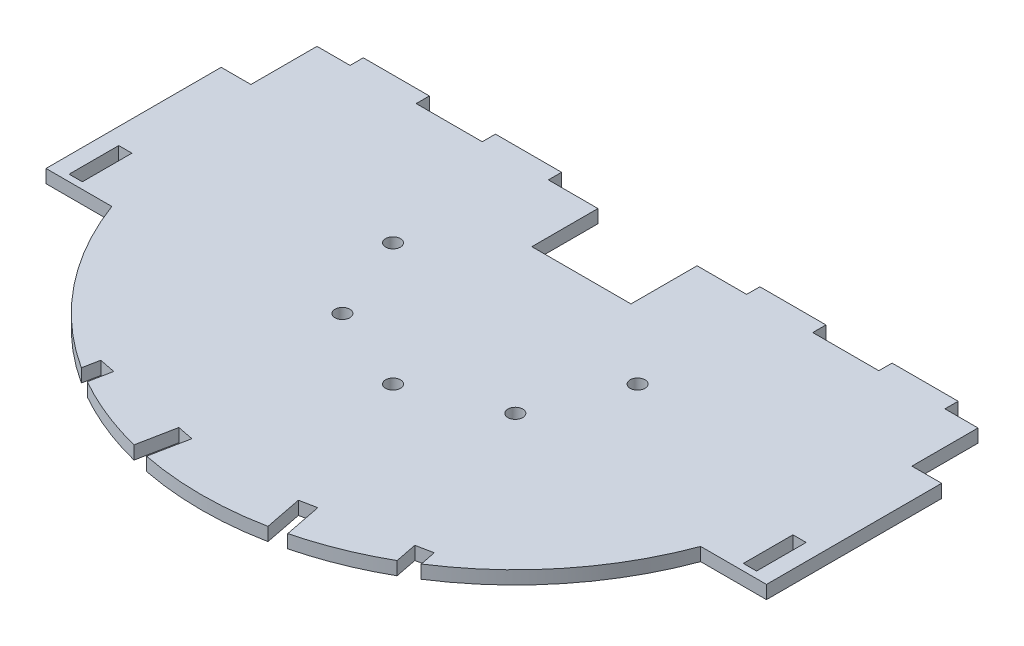
from build123d import *

# Parameters (mm, degrees)
SKICA1_W                = 4
SKICA1_H                = 15
SKICA1_R                = 2.25
P_IDAT_VYSUNUT_M1_DEPTH = 4


with BuildPart() as part:
    # Skica1 → Přidat vysunutím1 (new body)
    with BuildSketch(Plane(origin=(0, 0, 0), x_dir=(1, 0, 0), z_dir=(0, 1, 0))):
        with BuildLine():
            ThreePointArc((10.915770195, 0), (25.940686176, -26.499731394), (48.580654593, -46.881480444))
            Line((48.580654593, -46.881480444), (49.547625125, -41.975874672))
            Line((49.547625125, -41.975874672), (54.453230897, -42.942845204))
            Line((54.453230897, -42.942845204), (53.134056197, -49.635242551))
            ThreePointArc((53.134056197, -49.635242551), (64.622092485, -55.166907964), (76.747418364, -59.110354723))
            Line((76.747418364, -59.110354723), (78.981259757, -47.777697862))
            Line((78.981259757, -47.777697862), (83.886865529, -48.744668394))
            Line((83.886865529, -48.744668394), (81.627559896, -60.206509669))
            ThreePointArc((81.627559896, -60.206509669), (100, -62), (118.372440104, -60.206509669))
            Line((118.372440104, -60.206509669), (116.113134471, -48.744668394))
            Line((116.113134471, -48.744668394), (121.018740243, -47.777697862))
            Line((121.018740243, -47.777697862), (123.252581636, -59.110354723))
            ThreePointArc((123.252581636, -59.110354723), (135.377907515, -55.166907964), (146.865943803, -49.635242551))
            Line((146.865943803, -49.635242551), (145.546769103, -42.942845204))
            Line((145.546769103, -42.942845204), (150.452374875, -41.975874672))
            Line((150.452374875, -41.975874672), (151.419345407, -46.881480444))
            ThreePointArc((151.419345407, -46.881480444), (174.059313824, -26.499731394), (189.084229805, 0))
            Line((189.084229805, 0), (209, 0))
            Line((209, 0), (209, 53))
            Line((209, 53), (200, 53))
            Line((200, 53), (200, 73))
            Line((200, 73), (190, 73))
            Line((190, 73), (190, 77))
            Line((190, 77), (170, 77))
            Line((170, 77), (170, 73))
            Line((170, 73), (150, 73))
            Line((150, 73), (150, 77))
            Line((150, 77), (130, 77))
            Line((130, 77), (130, 73))
            Line((130, 73), (115, 73))
            Line((115, 73), (115, 53))
            Line((115, 53), (85, 53))
            Line((85, 53), (85, 73))
            Line((85, 73), (70, 73))
            Line((70, 73), (70, 77))
            Line((70, 77), (50, 77))
            Line((50, 77), (50, 73))
            Line((50, 73), (30, 73))
            Line((30, 73), (30, 77))
            Line((30, 77), (10, 77))
            Line((10, 77), (10, 73))
            Line((10, 73), (0, 73))
            Line((0, 73), (0, 53))
            Line((0, 53), (-9, 53))
            Line((-9, 53), (-9, 0))
            Line((-9, 0), (10.915770195, 0))
        make_face()
        with Locations((-2, 9.5)):
            Rectangle(SKICA1_W, SKICA1_H, mode=Mode.SUBTRACT)
        with Locations((73.837049096, 6.837049096)):
            Circle(SKICA1_R, mode=Mode.SUBTRACT)
        with Locations((100, -4)):
            Circle(SKICA1_R, mode=Mode.SUBTRACT)
        with Locations((126.162950904, 6.837049096)):
            Circle(SKICA1_R, mode=Mode.SUBTRACT)
        with Locations((202, 9.5)):
            Rectangle(SKICA1_W, SKICA1_H, mode=Mode.SUBTRACT)
        with Locations((63, 33)):
            Circle(SKICA1_R, mode=Mode.SUBTRACT)
        with Locations((137, 33)):
            Circle(SKICA1_R, mode=Mode.SUBTRACT)
    extrude(amount=P_IDAT_VYSUNUT_M1_DEPTH)


solid = part.part
